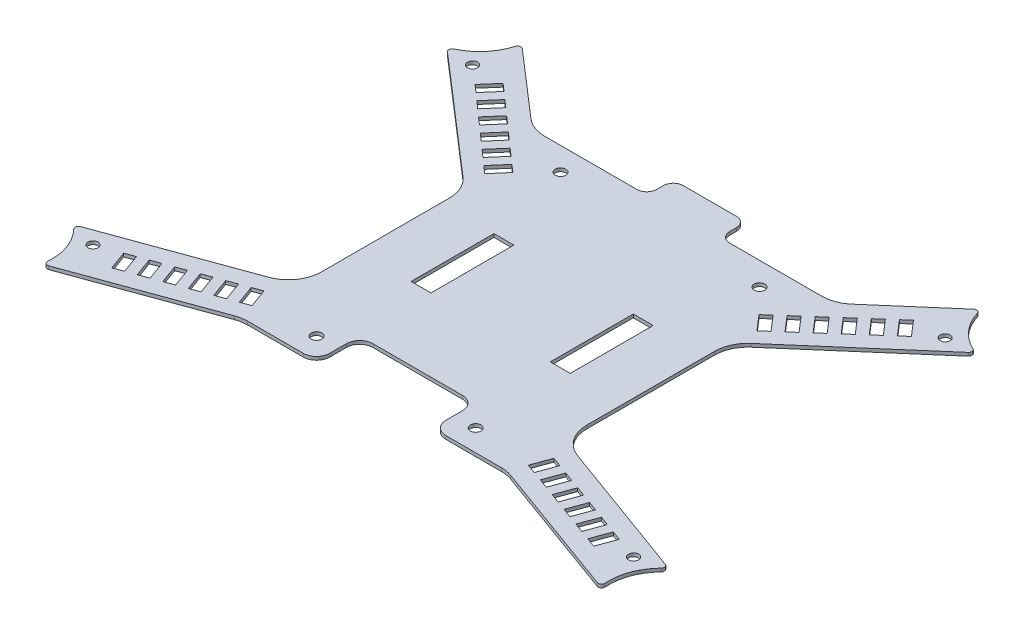
from build123d import *

# Parameters (mm, degrees)
BOSS_EXTRUDE1_DEPTH = 1
SKETCH5_R           = 1.6
CUT_EXTRUDE1_DEPTH  = 2.0000001
SKETCH6_W           = 6
SKETCH6_H           = 25
CUT_EXTRUDE2_DEPTH  = 2.0000001
CUT_EXTRUDE3_DEPTH  = 2.0000001
SKETCH8_R           = 1.5
CUT_EXTRUDE4_DEPTH  = 2.0000001


with BuildPart() as part:
    # Sketch2 → Boss-Extrude1 (new body)
    with BuildSketch(Plane(origin=(0, 0, 0), x_dir=(1, 0, 0), z_dir=(0, 1, 0))):
        with BuildLine():
            Line((11, 53), (11, 55))
            ThreePointArc((11, 55), (10.121320344, 57.121320344), (8, 58))
            Line((8, 58), (-8, 58))
            ThreePointArc((-8, 58), (-10.121320344, 57.121320344), (-11, 55))
            Line((-11, 55), (-11, 53))
            ThreePointArc((-11, 53), (-11.878679656, 50.878679656), (-14, 50))
            Line((-14, 50), (-41.793261547, 50))
            ThreePointArc((-41.793261547, 50), (-45.286330682, 50.629916328), (-48.33933156, 52.440306397))
            Line((-48.33933156, 52.440306397), (-68.051717018, 69.509603397))
            add(Edge.make_bspline(
                [(-68.051717018, 69.509603397), (-68.661066891, 70.037250037), (-69.434845107, 69.811450311), (-69.664775548, 69.03888948)],
                knots=[0, 0, 0, 0, 1, 1, 1, 1], degree=3, weights=[1, 0.694884096, 0.694884096, 1]))
            ThreePointArc((-69.664775548, 69.03888948), (-72.904490235, 63.129264551), (-78.290185448, 59.077881438))
            add(Edge.make_bspline(
                [(-78.290185448, 59.077881438), (-79.021933431, 58.739853135), (-79.134778913, 57.941740272), (-78.52542904, 57.414093632)],
                knots=[0, 0, 0, 0, 1, 1, 1, 1], degree=3, weights=[1, 0.694884096, 0.694884096, 1]))
            Line((-78.52542904, 57.414093632), (-43.453929986, 27.045073359))
            ThreePointArc((-43.453929986, 27.045073359), (-40.904377423, 23.641056587), (-40, 19.485379755))
            Line((-40, 19.485379755), (-40, -19.043311809))
            ThreePointArc((-40, -19.043311809), (-41.808479557, -24.779076172), (-46.579798567, -28.440238017))
            Line((-46.579798567, -28.440238017), (-88.178505663, -43.580929184))
            add(Edge.make_bspline(
                [(-88.178505663, -43.580929184), (-88.935945857, -43.856614869), (-89.115103173, -44.642503474), (-88.551986372, -45.219233665)],
                knots=[0, 0, 0, 0, 1, 1, 1, 1], degree=3, weights=[1, 0.694884096, 0.694884096, 1]))
            ThreePointArc((-88.551986372, -45.219233665), (-84.964918067, -50.924701133), (-84.045368013, -57.601065844))
            add(Edge.make_bspline(
                [(-84.045368013, -57.601065844), (-84.106025489, -58.404831305), (-83.463623564, -58.891696801), (-82.70618337, -58.616011116)],
                knots=[0, 0, 0, 0, 1, 1, 1, 1], degree=3, weights=[1, 0.694884096, 0.694884096, 1]))
            Line((-82.70618337, -58.616011116), (-41.656931626, -43.675305343))
            ThreePointArc((-41.656931626, -43.675305343), (-39.97321197, -43.22415402), (-38.236730193, -43.07223155))
            Line((-38.236730193, -43.07223155), (-21.5, -43.07223155))
            ThreePointArc((-21.5, -43.07223155), (-18.671572875, -41.900658675), (-17.5, -39.07223155))
            Line((-17.5, -39.07223155), (-17.5, -34.07223155))
            ThreePointArc((-17.5, -34.07223155), (-16.328427125, -31.243804426), (-13.5, -30.07223155))
            Line((-13.5, -30.07223155), (13.5, -30.07223155))
            ThreePointArc((13.5, -30.07223155), (16.328427125, -31.243804426), (17.5, -34.07223155))
            Line((17.5, -34.07223155), (17.5, -39.07223155))
            ThreePointArc((17.5, -39.07223155), (18.671572875, -41.900658675), (21.5, -43.07223155))
            Line((21.5, -43.07223155), (38.236730193, -43.07223155))
            ThreePointArc((38.236730193, -43.07223155), (39.97321197, -43.22415402), (41.656931626, -43.675305343))
            Line((41.656931626, -43.675305343), (82.70618337, -58.616011116))
            add(Edge.make_bspline(
                [(82.70618337, -58.616011116), (83.463623564, -58.891696801), (84.106025489, -58.404831305), (84.045368013, -57.601065844)],
                knots=[0, 0, 0, 0, 1, 1, 1, 1], degree=3, weights=[1, 0.694884096, 0.694884096, 1]))
            ThreePointArc((84.045368013, -57.601065844), (84.964918067, -50.924701133), (88.551986372, -45.219233665))
            add(Edge.make_bspline(
                [(88.551986372, -45.219233665), (89.115103173, -44.642503474), (88.935945857, -43.856614869), (88.178505663, -43.580929184)],
                knots=[0, 0, 0, 0, 1, 1, 1, 1], degree=3, weights=[1, 0.694884096, 0.694884096, 1]))
            Line((88.178505663, -43.580929184), (46.579798567, -28.440238017))
            ThreePointArc((46.579798567, -28.440238017), (41.808479557, -24.779076172), (40, -19.043311809))
            Line((40, -19.043311809), (40, 19.485379755))
            ThreePointArc((40, 19.485379755), (40.904377423, 23.641056587), (43.453929986, 27.045073359))
            Line((43.453929986, 27.045073359), (78.52542904, 57.414093632))
            add(Edge.make_bspline(
                [(78.52542904, 57.414093632), (79.134778913, 57.941740272), (79.021933431, 58.739853135), (78.290185448, 59.077881438)],
                knots=[0, 0, 0, 0, 1, 1, 1, 1], degree=3, weights=[1, 0.694884096, 0.694884096, 1]))
            ThreePointArc((78.290185448, 59.077881438), (72.904490235, 63.129264551), (69.664775548, 69.03888948))
            add(Edge.make_bspline(
                [(69.664775548, 69.03888948), (69.434845107, 69.811450311), (68.661066891, 70.037250037), (68.051717018, 69.509603397)],
                knots=[0, 0, 0, 0, 1, 1, 1, 1], degree=3, weights=[1, 0.694884096, 0.694884096, 1]))
            Line((68.051717018, 69.509603397), (48.33933156, 52.440306397))
            ThreePointArc((48.33933156, 52.440306397), (45.286330682, 50.629916328), (41.793261547, 50))
            Line((41.793261547, 50), (14, 50))
            ThreePointArc((14, 50), (11.878679656, 50.878679656), (11, 53))
        make_face()
    extrude(amount=BOSS_EXTRUDE1_DEPTH)

    # Sketch5 → Cut-Extrude1 (cut, through all)
    with BuildSketch(Plane(origin=(0, 1, 0), x_dir=(1, 0, 0), z_dir=(0, 1, 0))):
        with Locations((24, -36.57223155)):
            Circle(SKETCH5_R)
        with Locations((-24, -36.57223155)):
            Circle(SKETCH5_R)
        with Locations((-30, 43)):
            Circle(SKETCH5_R)
        with Locations((30, 43)):
            Circle(SKETCH5_R)
    extrude(amount=-CUT_EXTRUDE1_DEPTH, mode=Mode.SUBTRACT)

    # Sketch6 → Cut-Extrude2 (cut, through all)
    with BuildSketch(Plane(origin=(0, 1, 0), x_dir=(1, 0, 0), z_dir=(0, 1, 0))):
        with Locations((-21, 4.42776845)):
            Rectangle(SKETCH6_W, SKETCH6_H)
        with Locations((21, 4.42776845)):
            Rectangle(SKETCH6_W, SKETCH6_H)
    extrude(amount=-CUT_EXTRUDE2_DEPTH, mode=Mode.SUBTRACT)

    # Sketch7 → Cut-Extrude3 (cut, through all)
    with BuildSketch(Plane(origin=(0, 1, 0), x_dir=(1, 0, 0), z_dir=(0, 1, 0))):
        Polygon((-65.796678915, 53.006072454), (-61.869036907, 57.541888616), (-59.601128826, 55.578067611), (-63.528770834, 51.04225145), align=None)
        Polygon((-61.297727654, 49.036409576), (-57.370085645, 53.572225738), (-55.102177565, 51.608404734), (-59.029819573, 47.072588572), align=None)
        Polygon((-56.798776392, 45.066746698), (-52.871134384, 49.60256286), (-50.603226303, 47.638741856), (-54.530868311, 43.102925694), align=None)
        Polygon((-52.299825131, 41.09708382), (-48.372183122, 45.632899982), (-46.104275041, 43.669078978), (-50.03191705, 39.133262816), align=None)
        Polygon((-47.800873869, 37.127420942), (-43.873231861, 41.663237104), (-41.60532378, 39.6994161), (-45.532965788, 35.163599938), align=None)
        Polygon((-43.301922608, 33.157758065), (-39.374280599, 37.693574227), (-37.106372518, 35.729753222), (-41.034014527, 31.193937061), align=None)
        Polygon((41.034014527, 31.193937061), (43.301922608, 33.157758065), (39.374280599, 37.693574227), (37.106372518, 35.729753222), align=None)
        Polygon((45.532965788, 35.163599938), (47.800873869, 37.127420942), (43.873231861, 41.663237104), (41.60532378, 39.6994161), align=None)
        Polygon((50.03191705, 39.133262816), (52.299825131, 41.09708382), (48.372183122, 45.632899982), (46.104275041, 43.669078978), align=None)
        Polygon((54.530868311, 43.102925694), (56.798776392, 45.066746698), (52.871134384, 49.60256286), (50.603226303, 47.638741856), align=None)
        Polygon((59.029819573, 47.072588572), (61.297727654, 49.036409576), (57.370085645, 53.572225738), (55.102177565, 51.608404734), align=None)
        Polygon((63.528770834, 51.04225145), (65.796678915, 53.006072454), (61.869036907, 57.541888616), (59.601128826, 55.578067611), align=None)
        Polygon((-74.714667048, -44.001381551), (-72.662546188, -49.639537276), (-69.843468326, -48.613476846), (-71.895589186, -42.975321121), align=None)
        Polygon((-69.076511323, -41.949260691), (-67.024390463, -47.587416416), (-64.205312601, -46.561355986), (-66.257433461, -40.923200261), align=None)
        Polygon((-63.438355599, -39.897139831), (-61.386234739, -45.535295556), (-58.567156876, -44.509235126), (-60.619277736, -38.871079401), align=None)
        Polygon((-57.800199874, -37.845018971), (-55.748079014, -43.483174696), (-52.929001152, -42.457114266), (-54.981122011, -36.818958541), align=None)
        Polygon((-52.162044149, -35.792898111), (-50.109923289, -41.431053836), (-47.290845427, -40.404993406), (-49.342966287, -34.766837681), align=None)
        Polygon((-46.523888424, -33.740777251), (-44.471767564, -39.378932976), (-41.652689702, -38.352872546), (-43.704810562, -32.714716821), align=None)
        Polygon((43.704810562, -32.714716821), (46.523888424, -33.740777251), (44.471767564, -39.378932976), (41.652689702, -38.352872546), align=None)
        Polygon((49.342966287, -34.766837681), (52.162044149, -35.792898111), (50.109923289, -41.431053836), (47.290845427, -40.404993406), align=None)
        Polygon((54.981122011, -36.818958541), (57.800199874, -37.845018971), (55.748079014, -43.483174696), (52.929001152, -42.457114266), align=None)
        Polygon((60.619277736, -38.871079401), (63.438355599, -39.897139831), (61.386234739, -45.535295556), (58.567156876, -44.509235126), align=None)
        Polygon((66.257433461, -40.923200261), (69.076511323, -41.949260691), (67.024390463, -47.587416416), (64.205312601, -46.561355986), align=None)
        Polygon((71.895589186, -42.975321121), (74.714667048, -44.001381551), (72.662546188, -49.639537276), (69.843468326, -48.613476846), align=None)
    extrude(amount=-CUT_EXTRUDE3_DEPTH, mode=Mode.SUBTRACT)

    # Sketch8 → Cut-Extrude4 (cut, through all)
    with BuildSketch(Plane(origin=(0, 1, 0), x_dir=(1, 0, 0), z_dir=(0, 1, 0))):
        with Locations((-81.494916078, -46.469190379)):
            Circle(SKETCH8_R)
        with Locations((-71.251292912, 57.729317468)):
            Circle(SKETCH8_R)
        with Locations((71.251292912, 57.729317468)):
            Circle(SKETCH8_R)
        with Locations((81.494916078, -46.469190379)):
            Circle(SKETCH8_R)
    extrude(amount=-CUT_EXTRUDE4_DEPTH, mode=Mode.SUBTRACT)


solid = part.part
